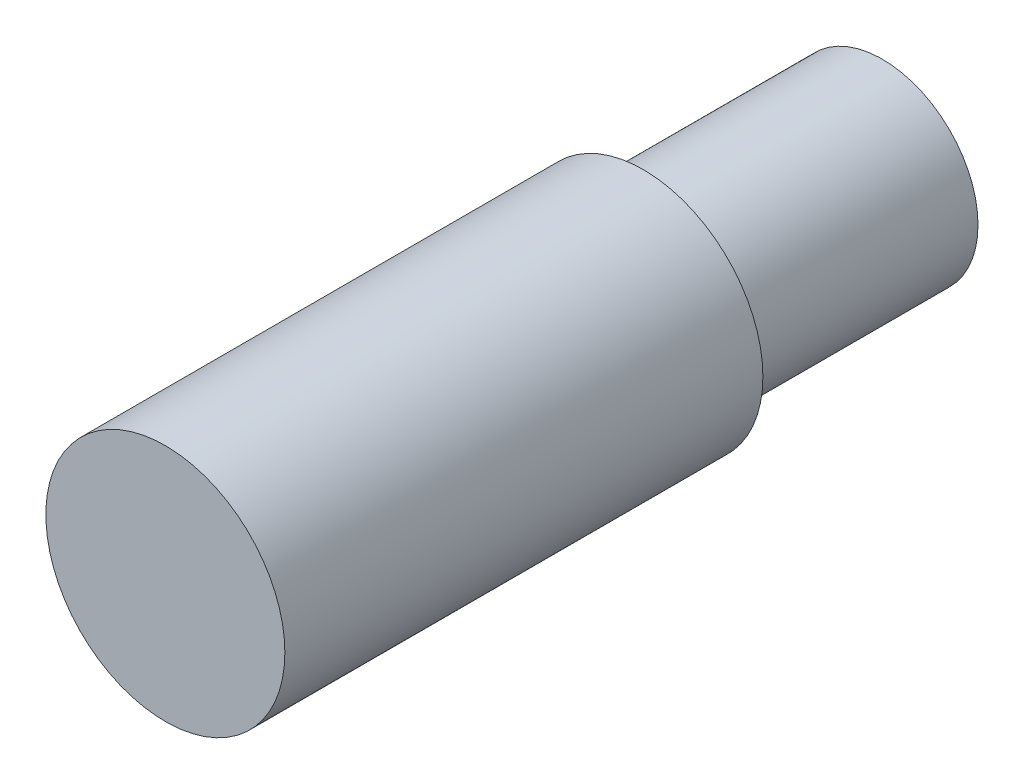
from build123d import *

# Parameters (mm, degrees)
SKETCH1_R      = 2
EXTRUDE1_DEPTH = 5
SKETCH2_R      = 2.5
EXTRUDE2_DEPTH = 10


with BuildPart() as part:
    # Sketch1 → Extrude1 (new body)
    with BuildSketch(Plane.XY):
        Circle(SKETCH1_R)
    extrude(amount=EXTRUDE1_DEPTH)

    # Sketch2 → Extrude2 (add)
    with BuildSketch(Plane.XY.offset(5)):
        Circle(SKETCH2_R)
    extrude(amount=EXTRUDE2_DEPTH)


solid = part.part
